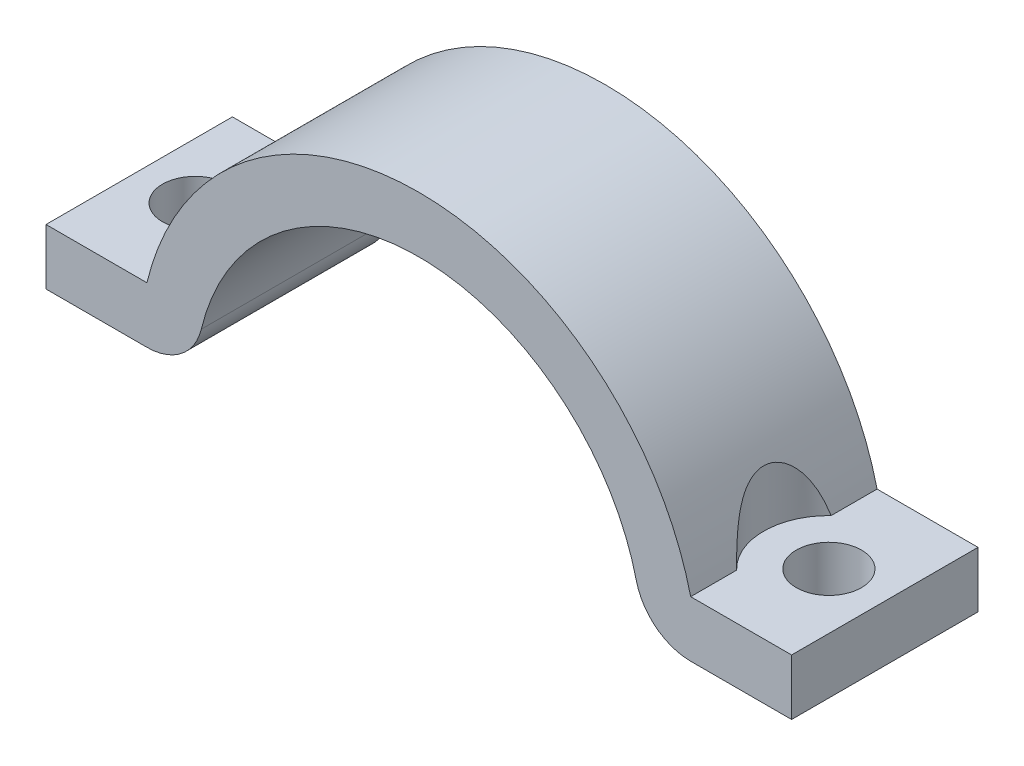
from build123d import *

# Parameters (mm, degrees)
BOSS_EXTRU_2_DEPTH      = 10
ESQUISSE3_R             = 1.75
ENL_V_MAT_EXTRU_2_DEPTH = 4
ESQUISSE4_R             = 3.5
ENL_V_MAT_EXTRU_3_DEPTH = 12.5


with BuildPart() as part:
    # Esquisse1 → Boss.-Extru.2 (new body)
    with BuildSketch(Plane.XY):
        with BuildLine():
            Line((-20, 0.5), (-14.585952146, 0.5))
            ThreePointArc((-14.585952146, 0.5), (-12.728534584, 1.144156202), (-11.668761717, 2.8))
            ThreePointArc((-11.668761717, 2.8), (0, 12), (11.668761717, 2.8))
            ThreePointArc((11.668761717, 2.8), (12.728534584, 1.144156202), (14.585952146, 0.5))
            Line((14.585952146, 0.5), (20, 0.5))
            Line((20, 0.5), (20, 3.5))
            Line((20, 3.5), (14.585952146, 3.5))
            ThreePointArc((14.585952146, 3.5), (0, 15), (-14.585952146, 3.5))
            Line((-14.585952146, 3.5), (-20, 3.5))
            Line((-20, 3.5), (-20, 0.5))
        make_face()
    extrude(amount=BOSS_EXTRU_2_DEPTH)

    # Esquisse3 → Enlèv. mat.-Extru.2 (cut, through all)
    with BuildSketch(Plane(origin=(0, 3.5, 0), x_dir=(1, 0, 0), z_dir=(0, 1, 0))):
        with Locations((-17, -5)):
            Circle(ESQUISSE3_R)
        with Locations((17, -5)):
            Circle(ESQUISSE3_R)
    extrude(amount=-ENL_V_MAT_EXTRU_2_DEPTH, mode=Mode.SUBTRACT)

    # Esquisse4 → Enlèv. mat.-Extru.3 (cut, through all)
    with BuildSketch(Plane(origin=(0, 3.5, 0), x_dir=(1, 0, 0), z_dir=(0, 1, 0))):
        with Locations((-17, -5)):
            Circle(ESQUISSE4_R)
        with Locations((17, -5)):
            Circle(ESQUISSE4_R)
    extrude(amount=ENL_V_MAT_EXTRU_3_DEPTH, mode=Mode.SUBTRACT)


solid = part.part
